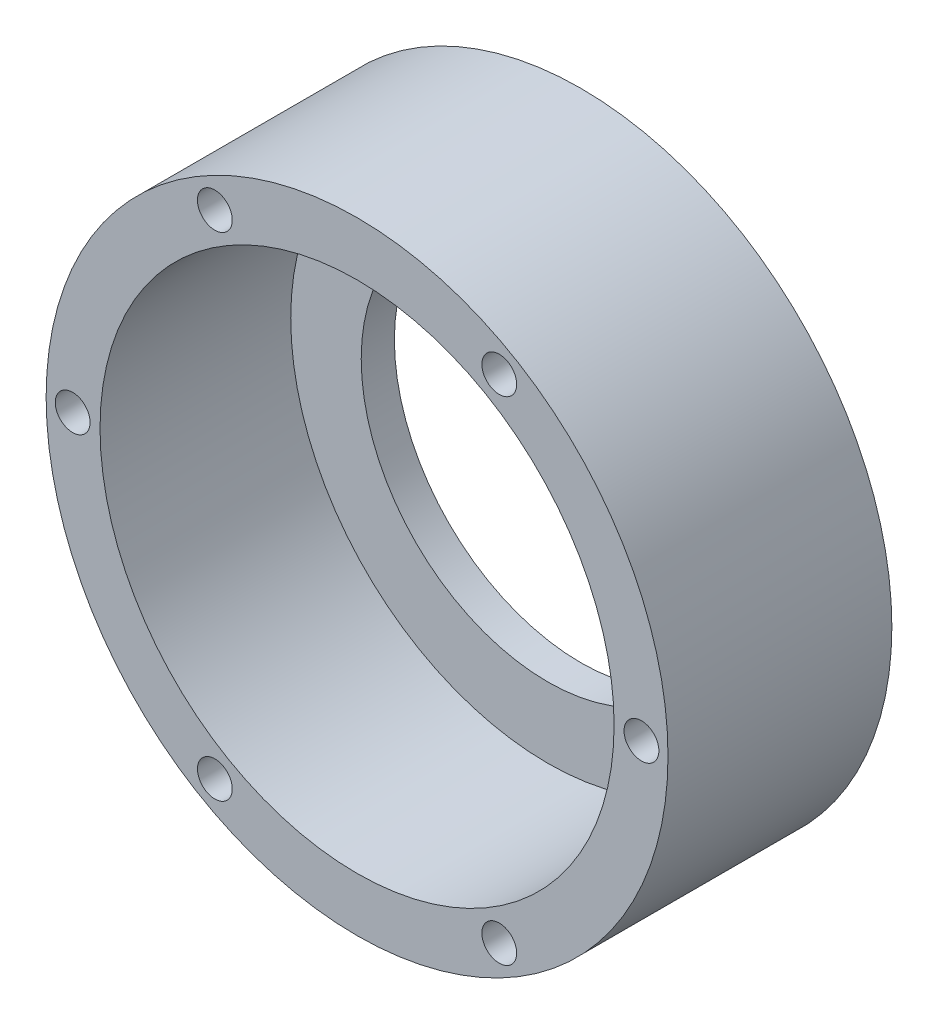
from build123d import *

# Parameters (mm, degrees)
CROQUIS1_R              = 37.5
SALIENTE_EXTRUIR1_DEPTH = 27
CROQUIS2_R              = 31
CORTAR_EXTRUIR1_DEPTH   = 23
CROQUIS3_R              = 22.5
CORTAR_EXTRUIR2_DEPTH   = 23
TALADRO_ROSCADO_M51_D   = 4.2
MATRIZC1_COUNT          = 6


with BuildPart() as part:
    # Croquis1 → Saliente-Extruir1 (new body)
    with BuildSketch(Plane.XY):
        Circle(CROQUIS1_R)
    extrude(amount=SALIENTE_EXTRUIR1_DEPTH)

    # Croquis2 → Cortar-Extruir1 (cut)
    with BuildSketch(Plane.XY.offset(27)):
        Circle(CROQUIS2_R)
    extrude(amount=-CORTAR_EXTRUIR1_DEPTH, mode=Mode.SUBTRACT)

    # Croquis3 → Cortar-Extruir2 (cut)
    with BuildSketch(Plane.XY.offset(4)):
        Circle(CROQUIS3_R)
    extrude(amount=-CORTAR_EXTRUIR2_DEPTH, mode=Mode.SUBTRACT)

    # Taladro roscado M51 (through all)
    with Locations(Plane.XY.offset(27)):
        with Locations((-34.3, 0)):
            taladro_roscado_m51 = Hole(TALADRO_ROSCADO_M51_D / 2)

    # MatrizC1: Taladro roscado M51 ×6 about axis
    matrizc1_axis = Axis((0, 0, 0), (0, 0, 1))
    for i in range(1, MATRIZC1_COUNT):
        add(taladro_roscado_m51.rotate(matrizc1_axis, i * 360 / MATRIZC1_COUNT), mode=Mode.SUBTRACT)


solid = part.part
